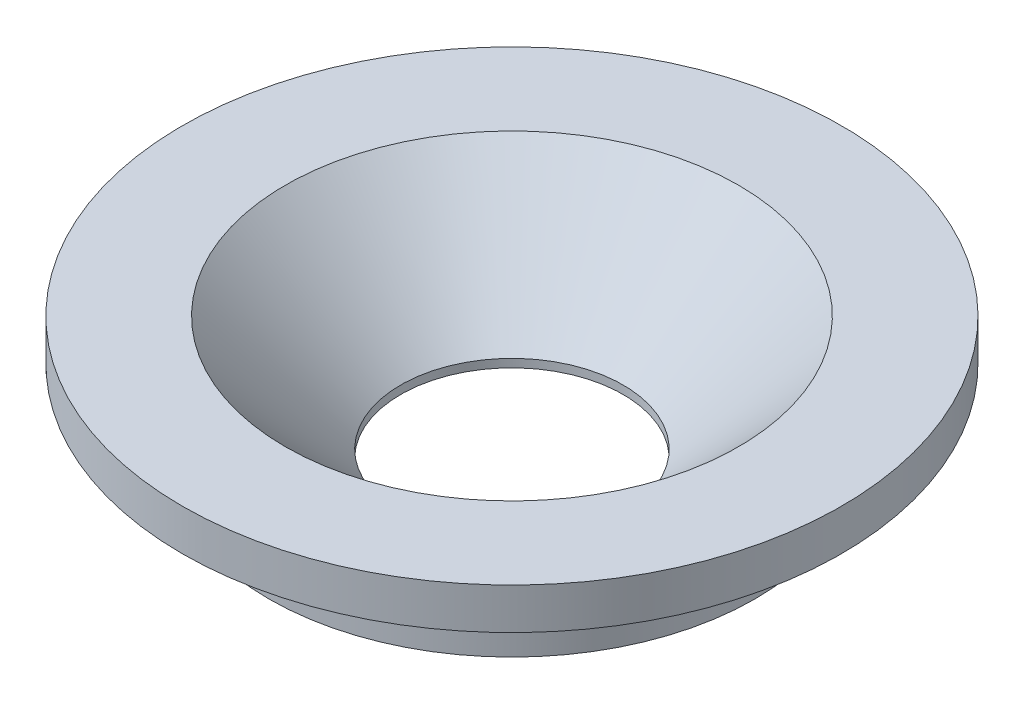
from build123d import *

# Parameters (mm, degrees)
SKETCH1_R           = 2.95
BOSS_EXTRUDE1_DEPTH = 1
SKETCH2_R           = 4
BOSS_EXTRUDE2_DEPTH = 0.5


with BuildPart() as part:
    # Sketch1 → Boss-Extrude1 (new body)
    with BuildSketch(Plane(origin=(0, 0, 0), x_dir=(1, 0, 0), z_dir=(0, 1, 0))):
        Circle(SKETCH1_R)
    extrude(amount=BOSS_EXTRUDE1_DEPTH)

    # Sketch2 → Boss-Extrude2 (add)
    with BuildSketch(Plane(origin=(0, 1, 0), x_dir=(1, 0, 0), z_dir=(0, 1, 0))):
        Circle(SKETCH2_R)
    extrude(amount=BOSS_EXTRUDE2_DEPTH)

    # Sketch3 → CSK for M2.5 Flat Head Machine Screw1 (revolve, cut)
    with BuildSketch(Plane(origin=(0, 1.5, 0), x_dir=(0, 0, 1), z_dir=(1, 0, 0))):
        Polygon((0, 0), (0, 2.311161836), (1.35, 1.5), (1.35, 1.4), (2.75, 0), align=None)
    revolve(axis=Axis((0, 7.85, 0), (0, -1, 0)), mode=Mode.SUBTRACT)


solid = part.part
